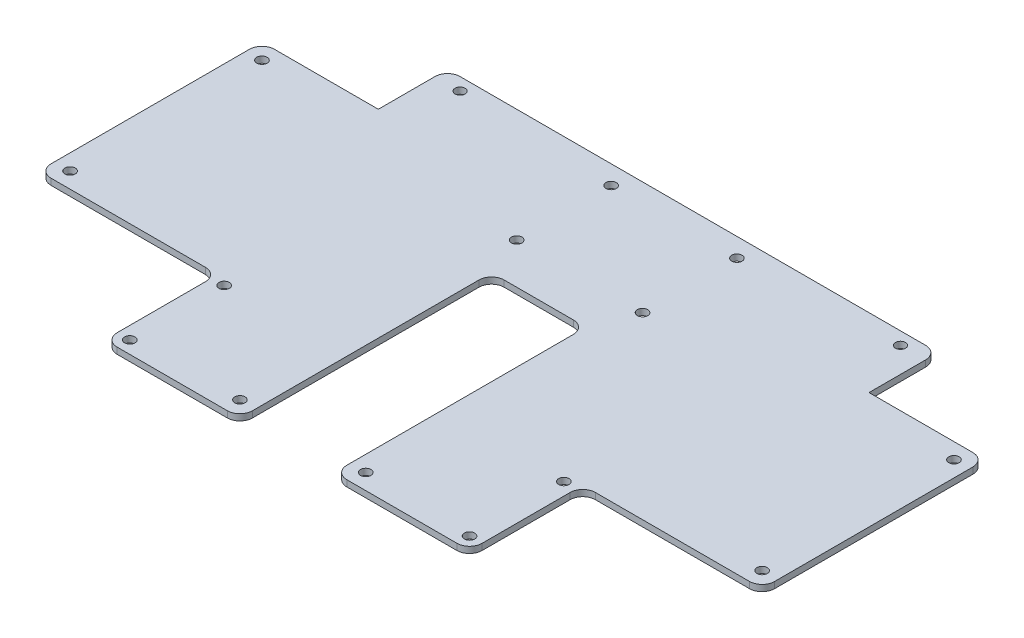
from build123d import *

# Parameters (mm, degrees)
SKETCH1_W           = 230
SKETCH1_H           = 129
BOSS_EXTRUDE1_DEPTH = 2
SKETCH2_W           = 37
SKETCH2_H           = 22
SKETCH2_W_2         = 57
SKETCH2_H_2         = 36
SKETCH2_W_3         = 30
SKETCH2_H_3         = 80
CUT_EXTRUDE1_DEPTH  = 3
SKETCH3_R           = 1.65
SKETCH3_R_2         = 1.6
CUT_EXTRUDE2_DEPTH  = 10
FILLET1_R           = 4


with BuildPart() as part:
    # Sketch1 → Boss-Extrude1 (new body)
    with BuildSketch(Plane(origin=(0, 0, 0), x_dir=(1, 0, 0), z_dir=(0, 1, 0))):
        with Locations((115, 64.5)):
            Rectangle(SKETCH1_W, SKETCH1_H)
    extrude(amount=BOSS_EXTRUDE1_DEPTH)

    # Sketch2 → Cut-Extrude1 (cut, through all)
    with BuildSketch(Plane(origin=(0, 2, 0), x_dir=(1, 0, 0), z_dir=(0, 1, 0))):
        with Locations((18.5, 118)):
            Rectangle(SKETCH2_W, SKETCH2_H)
        with Locations((28.5, 18)):
            Rectangle(SKETCH2_W_2, SKETCH2_H_2)
        with Locations((211.5, 118)):
            Rectangle(SKETCH2_W, SKETCH2_H)
        with Locations((201.5, 18)):
            Rectangle(SKETCH2_W_2, SKETCH2_H_2)
        with Locations((115, 40)):
            Rectangle(SKETCH2_W_3, SKETCH2_H_3)
    extrude(amount=-CUT_EXTRUDE1_DEPTH, mode=Mode.SUBTRACT)

    # Sketch3 → Cut-Extrude2 (cut)
    with BuildSketch(Plane.XZ):
        with Locations((5, -41)):
            Circle(SKETCH3_R)
        with Locations((5, -102)):
            Circle(SKETCH3_R)
        with Locations((95, -5)):
            Circle(SKETCH3_R)
        with Locations((95, -93)):
            Circle(SKETCH3_R)
        with Locations((95, -123)):
            Circle(SKETCH3_R)
        with Locations((135, -93)):
            Circle(SKETCH3_R)
        with Locations((135, -5)):
            Circle(SKETCH3_R)
        with Locations((135, -123)):
            Circle(SKETCH3_R)
        with Locations((225, -41)):
            Circle(SKETCH3_R)
        with Locations((225, -102)):
            Circle(SKETCH3_R)
        with Locations((61, -34)):
            Circle(SKETCH3_R)
        with Locations((61, -4)):
            Circle(SKETCH3_R)
        with Locations((169, -34)):
            Circle(SKETCH3_R)
        with Locations((169, -4)):
            Circle(SKETCH3_R)
        with Locations((45, -125)):
            Circle(SKETCH3_R_2)
        with Locations((185, -125)):
            Circle(SKETCH3_R_2)
    extrude(amount=-CUT_EXTRUDE2_DEPTH, mode=Mode.SUBTRACT)

    # Fillet1
    fillet1_edges = [part.edges().sort_by_distance(p)[0] for p in [
        (0, 1, -36),
        (57, 1, -36),
        (57, 1, 0),
        (230, 1, -107),
        (193, 1, -129),
        (230, 1, -36),
        (173, 1, 0),
        (173, 1, -36),
        (100, 1, 0),
        (100, 1, -80),
        (130, 1, -80),
        (130, 1, 0),
        (0, 1, -107),
        (37, 1, -129),
    ]]
    fillet(fillet1_edges, radius=FILLET1_R)


solid = part.part
